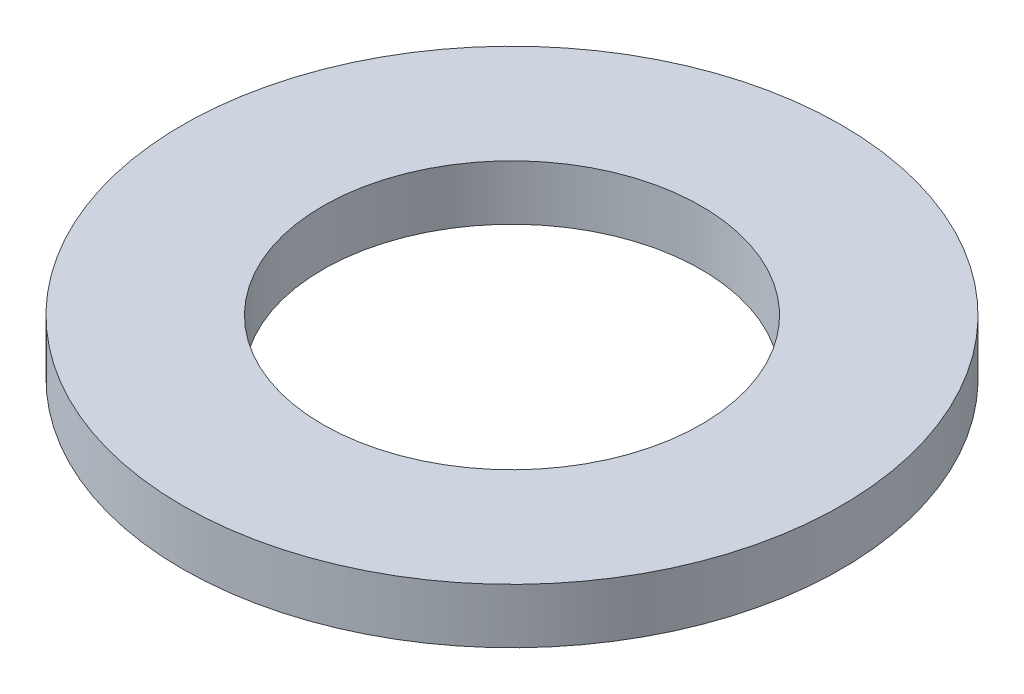
from build123d import *

# Parameters (mm, degrees)
SKETCH1_R           = 1.524
SKETCH1_R_2         = 0.875
BOSS_EXTRUDE1_DEPTH = 0.254


with BuildPart() as part:
    # Sketch1 → Boss-Extrude1 (new body)
    with BuildSketch(Plane(origin=(0, 0, 0), x_dir=(1, 0, 0), z_dir=(0, 1, 0))):
        Circle(SKETCH1_R)
        Circle(SKETCH1_R_2, mode=Mode.SUBTRACT)
    extrude(amount=BOSS_EXTRUDE1_DEPTH)


solid = part.part
